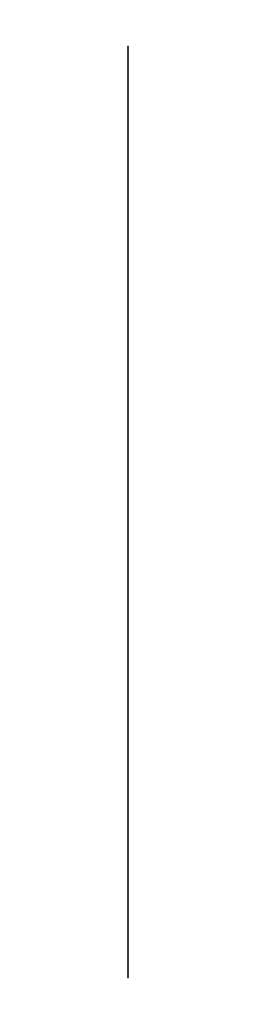
from build123d import *

# Parameters (mm, degrees)
SKETCH_1_R      = 1
EXTRUDE_1_DEPTH = 2000


with BuildPart() as part:
    # 草图1 → 凸台-拉伸1 (new body)
    with BuildSketch(Plane(origin=(0, 0, 0), x_dir=(1, 0, 0), z_dir=(0, 1, 0))):
        Circle(SKETCH_1_R)
    extrude(amount=EXTRUDE_1_DEPTH)


solid = part.part
